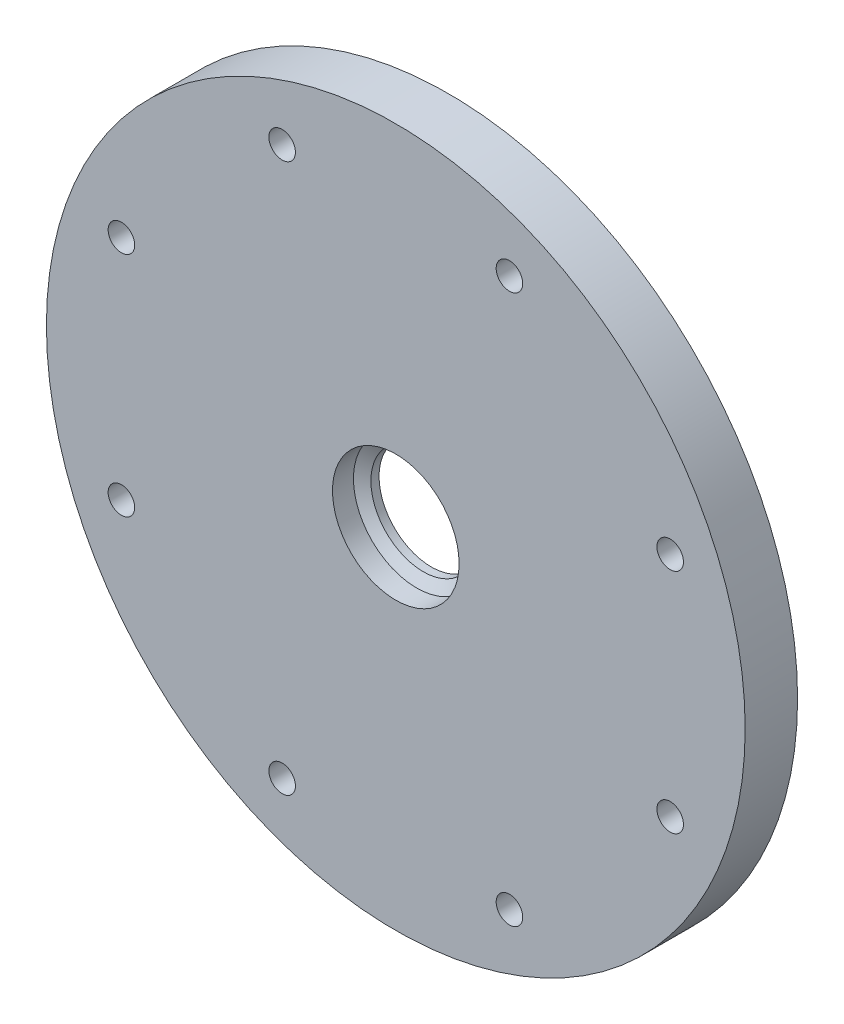
from build123d import *

# Parameters (mm, degrees)
SKETCH1_R                         = 63.5
SKETCH1_R_2                       = 9.525
BOSS_EXTRUDE1_DEPTH               = 9.525
SKETCH4_R                         = 2.413
CUT_EXTRUDE1_DEPTH                = 10.525
CIRPATTERN1_COUNT                 = 8
SKETCH7_R                         = 33.02
BOSS_EXTRUDE4_DEPTH               = 4.826
SKETCH9_R                         = 33.02
CUT_EXTRUDE2_DEPTH                = 3.048
PIPE_TAP_DRILL_FOR_3_4_TAP4_D     = 23.0124
PIPE_TAP_DRILL_FOR_3_4_TAP4_DEPTH = 3.81
PIPE_TAP_DRILL_FOR_3_4_TAP4_TIP   = 6.913622455


with BuildPart() as part:
    # Sketch1 → Boss-Extrude1 (new body)
    with BuildSketch(Plane.XY):
        Circle(SKETCH1_R)
        Circle(SKETCH1_R_2, mode=Mode.SUBTRACT)
    extrude(amount=BOSS_EXTRUDE1_DEPTH)

    # Sketch4 → Cut-Extrude1 (cut, through all)
    with BuildSketch(Plane.XY.offset(9.525)):
        with Locations((49.866397767, 20.655338262)):
            Circle(SKETCH4_R)
    cut_extrude1 = extrude(amount=-CUT_EXTRUDE1_DEPTH, mode=Mode.SUBTRACT)

    # CirPattern1: Cut-Extrude1 ×8 about axis
    cirpattern1_axis = Axis((0, 0, 0), (0, 0, 1))
    for i in range(1, CIRPATTERN1_COUNT):
        add(cut_extrude1.rotate(cirpattern1_axis, i * 360 / CIRPATTERN1_COUNT), mode=Mode.SUBTRACT)

    # Sketch7 → Boss-Extrude4 (add)
    with BuildSketch(Plane.XY):
        with BuildLine():
            ThreePointArc((44.898742199, 0), (44.018213285, 2.330669915), (41.72653773, 3.308205888))
            Line((41.72653773, 3.308205888), (38.377645632, 3.308205888))
            ThreePointArc((38.377645632, 3.308205888), (36.132581602, 2.378269918), (35.202645632, 0.133205888))
            ThreePointArc((35.202645632, 0.133205888), (34.829644744, -0.48063442), (34.295865632, 0))
            add(Edge.make_bspline(
                [(34.295865632, 0), (34.29882834, 0.071916436), (34.304754577, 0.21576926), (34.311966888, 0.431642324), (34.317934755, 0.647612083), (34.327139988, 1.079917114), (34.332942166, 2.090306576), (34.279898225, 3.607362054), (34.120445155, 5.41030125), (33.960201682, 6.560746683), (33.865422793, 7.135076209), (33.865142183, 7.136775827)],
                knots=[0, 0, 0, 0, 0.000870248, 0.001740737, 0.002611466, 0.003482435, 0.006968712, 0.014826916, 0.02182843, 0.028845498, 0.028866325, 0.028866325, 0.028866325, 0.028866325], degree=3))
            add(Edge.make_bspline(
                [(33.865142183, 7.136775827), (33.7706713, 7.708973751), (33.552478291, 8.851599937), (33.138997804, 10.54970943), (32.639140351, 12.230302519), (32.054174895, 13.887355713), (31.385187056, 15.516557503), (30.633483645, 17.113645751), (29.800589951, 18.674419055), (28.8882464, 20.194747988), (27.898404875, 21.670586138), (26.833224521, 23.097980967), (25.695067067, 24.473084443), (24.486491635, 25.79216345), (23.210249051, 27.051609932), (21.869275652, 28.247950753), (20.466686605, 29.377857252), (19.005768742, 30.438154464), (17.489972932, 31.425829986), (15.922906004, 32.338042467), (14.30832223, 33.172129685), (12.650114403, 33.925616212), (10.95230451, 34.596220626), (9.219034045, 35.18186226), (7.454553956, 35.680667464), (5.663214286, 36.090975363), (3.849453494, 36.411343101), (2.017787512, 36.640550541), (0.172798549, 36.777604421), (-1.680876324, 36.82174194), (-3.538556782, 36.772433779), (-5.395531021, 36.629386524), (-7.247067665, 36.392544506), (-9.088427776, 36.062091031), (-10.914876942, 35.638449008), (-12.721697408, 35.122280961), (-14.504200214, 34.514488429), (-16.257737325, 33.816210747), (-17.977713699, 33.028823219), (-19.659599284, 32.153934663), (-21.298940898, 31.193384362), (-22.891373965, 30.149238397), (-24.43263408, 29.02378539), (-25.918568367, 27.819531655), (-27.345146601, 26.539195761), (-28.708472073, 25.185702541), (-30.004792148, 23.762176529), (-31.230508517, 22.271934869), (-32.382187085, 20.718479685), (-33.456567491, 19.105489956), (-34.450572223, 17.436812889), (-35.361315302, 15.716454831), (-36.186110516, 13.948571725), (-36.92247918, 12.137459144), (-37.568157395, 10.287541924), (-38.121102788, 8.403363415), (-38.579500717, 6.489574383), (-38.941769921, 4.550921586), (-39.206567586, 2.592236057), (-39.372793836, 0.618421113), (-39.439595611, -1.36555987), (-39.406369933, -3.354695889), (-39.272766542, -5.343940927), (-39.038689903, -7.328226707), (-38.704300556, -9.302475561), (-38.270015827, -11.261613379), (-37.736509879, -13.200582609), (-37.104713104, -15.11435526), (-36.375810853, -16.997945903), (-35.551241515, -18.846424601), (-34.632693929, -20.654929769), (-33.622104149, -22.418680905), (-32.521651558, -24.132991168), (-31.333754343, -25.793279776), (-30.061064337, -27.395084183), (-28.706461239, -28.934071999), (-27.273046228, -30.406052641), (-25.764134977, -31.806988658), (-24.18325009, -33.133006716), (-22.534112978, -34.380408214), (-20.820635184, -35.545679488), (-19.046909189, -36.625501594), (-17.217198713, -37.616759627), (-15.335928538, -38.516551562), (-13.407673866, -39.322196576), (-11.437149261, -40.031242854), (-9.429197172, -40.641474829), (-7.388776087, -41.15091985), (-5.32094834, -41.557854256), (-3.230867597, -41.86080884), (-1.123766056, -42.058573678), (0.995058608, -42.150202316), (3.120256518, -42.135015304), (5.246439066, -42.01260305), (7.368192535, -41.782828005), (9.480091844, -41.445826152), (11.576714375, -41.002007803), (13.652653862, -40.452057696), (15.702534288, -39.796934391), (17.72102376, -39.037868953), (19.702848338, -38.176362944), (21.642805765, -37.214185701), (23.535779073, -36.153370925), (25.376750026, -34.996212572), (27.16081237, -33.745260064), (28.883184839, -32.403312824), (30.539223912, -30.973414146), (32.12443625, -29.458844418), (33.634490817, -27.863113704), (35.065230621, -26.189953715), (36.412684063, -24.44330917), (37.673075861, -22.62732858), (38.842837509, -20.746354475), (39.91861725, -18.804913085), (40.897289536, -16.807703518), (41.775963949, -14.759586443), (42.55199355, -12.665572318), (43.22298264, -10.530809183), (43.786793912, -8.360570051), (44.241554967, -6.16023993), (44.571284542, -4.028278167), (44.740560267, -2.440845712), (44.813728039, -1.50376068), (44.839477521, -1.128293226), (44.857032226, -0.846470241), (44.872782179, -0.564469795), (44.886887576, -0.282309503), (44.894790326, -0.094111086), (44.898742199, 0)],
                knots=[0.028866325, 0.028866325, 0.028866325, 0.028866325, 0.035878186, 0.042926556, 0.049990663, 0.057070561, 0.064166299, 0.071277925, 0.078405484, 0.085549018, 0.092708569, 0.099884178, 0.107075882, 0.11428372, 0.121507729, 0.128747942, 0.136004396, 0.143277124, 0.150566158, 0.157871532, 0.165193276, 0.172531421, 0.179885999, 0.187257038, 0.194644569, 0.202048619, 0.209469218, 0.216906393, 0.224360171, 0.23183058, 0.239317647, 0.246821397, 0.254341857, 0.261879053, 0.269433009, 0.277003751, 0.284591303, 0.292195691, 0.299816937, 0.307455067, 0.315110103, 0.32278207, 0.33047099, 0.338176886, 0.345899781, 0.353639698, 0.361396658, 0.369170685, 0.376961799, 0.384770023, 0.392595378, 0.400437886, 0.408297568, 0.416174444, 0.424068536, 0.431979864, 0.439908449, 0.447854312, 0.455817472, 0.463797949, 0.471795764, 0.479810937, 0.487843486, 0.495893432, 0.503960795, 0.512045592, 0.520147845, 0.52826757, 0.536404789, 0.544559519, 0.552731779, 0.560921587, 0.569128963, 0.577353925, 0.58559649, 0.593856678, 0.602134505, 0.610429991, 0.618743153, 0.627074009, 0.635422576, 0.643788872, 0.652172916, 0.660574723, 0.668994312, 0.677431699, 0.685886903, 0.69435994, 0.702850826, 0.71135958, 0.719886217, 0.728430756, 0.736993211, 0.745573601, 0.754171941, 0.762788249, 0.771422539, 0.78007483, 0.788745137, 0.797433476, 0.806139864, 0.814864316, 0.823606849, 0.832367479, 0.841146221, 0.849943091, 0.858758106, 0.86759128, 0.87644263, 0.885312171, 0.894199918, 0.903105888, 0.912030094, 0.920972554, 0.929933282, 0.938912294, 0.947909603, 0.956925227, 0.96595918, 0.975011476, 0.984082132, 0.992034027, 0.994308583, 0.995446291, 0.996584287, 0.997722571, 0.998861142, 1, 1, 1, 1], degree=3))
        make_face()
        Circle(SKETCH7_R, mode=Mode.SUBTRACT)
        with BuildLine():
            ThreePointArc((35.202645632, 0.133205888), (36.132581602, 2.378269918), (38.377645632, 3.308205888))
            ThreePointArc((38.377645632, 3.308205888), (35.418733874, 4.394308044), (33.865142183, 7.136775827))
            add(Edge.make_bspline(
                [(34.295865632, 0), (34.29882834, 0.071916436), (34.304754577, 0.21576926), (34.311966888, 0.431642324), (34.317934755, 0.647612083), (34.327139988, 1.079917114), (34.332942166, 2.090306576), (34.279898225, 3.607362054), (34.120445155, 5.41030125), (33.960201682, 6.560746683), (33.865422793, 7.135076209), (33.865142183, 7.136775827)],
                knots=[0, 0, 0, 0, 0.000870248, 0.001740737, 0.002611466, 0.003482435, 0.006968712, 0.014826916, 0.02182843, 0.028845498, 0.028866325, 0.028866325, 0.028866325, 0.028866325], degree=3))
            ThreePointArc((34.295865632, 0), (34.829644744, -0.48063442), (35.202645632, 0.133205888))
        make_face()
    extrude(amount=-BOSS_EXTRUDE4_DEPTH)

    # Sketch9 → Cut-Extrude2 (cut)
    with BuildSketch(Plane(origin=(0, 0, 0), x_dir=(-1, 0, 0), z_dir=(0, 0, -1))):
        Circle(SKETCH9_R)
    extrude(amount=-CUT_EXTRUDE2_DEPTH, mode=Mode.SUBTRACT)

    # Pipe Tap Drill for 3/4 Tap4
    with Locations(Plane.XY.offset(9.525)):
        with Locations((0, 0)):
            Hole(PIPE_TAP_DRILL_FOR_3_4_TAP4_D / 2, depth=PIPE_TAP_DRILL_FOR_3_4_TAP4_DEPTH)
            with Locations((0, 0, -(PIPE_TAP_DRILL_FOR_3_4_TAP4_DEPTH + PIPE_TAP_DRILL_FOR_3_4_TAP4_TIP / 2))):  # 118° drill point
                Cone(0, PIPE_TAP_DRILL_FOR_3_4_TAP4_D / 2, PIPE_TAP_DRILL_FOR_3_4_TAP4_TIP, mode=Mode.SUBTRACT)


solid = part.part
